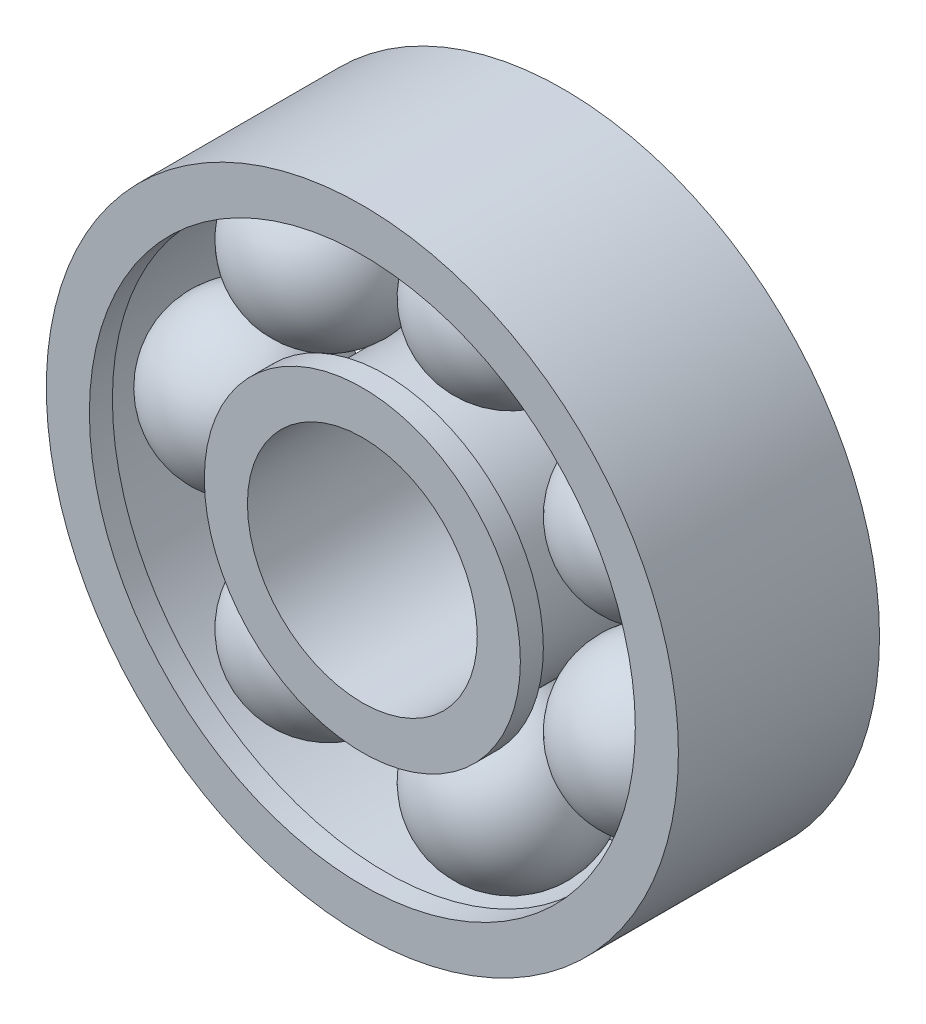
from build123d import *

# Parameters (mm, degrees)
BOSS_EXTRUDE1_DEPTH        = 3.5
BOSS_EXTRUDE1_DEPTH_BACK   = 3.5
SKETCH1_R                  = 5.5
SKETCH1_R_2                = 4
BOSS_EXTRUDE1_2_DEPTH      = 3.5
BOSS_EXTRUDE1_2_DEPTH_BACK = 3.5
SKETCH1_R_3                = 11
SKETCH1_R_4                = 9.5
CUT_EXTRUDE1_DEPTH         = 2.7
CUT_EXTRUDE1_DEPTH_BACK    = 2.7
SKETCH2_R                  = 10.3
SKETCH2_R_2                = 4.697673259


with BuildPart() as part:
    # Sketch1 → Boss-Extrude1 (new, two sides: drawn at the far end of the back side and taken through both)
    with BuildSketch(Plane.XY.offset(-BOSS_EXTRUDE1_DEPTH_BACK)):
        Circle(SKETCH1_R)
        Circle(SKETCH1_R_2, mode=Mode.SUBTRACT)
    extrude(amount=BOSS_EXTRUDE1_DEPTH + BOSS_EXTRUDE1_DEPTH_BACK)


with BuildPart() as body_2:
    # Sketch1 → Boss-Extrude1 2 (new, two sides: drawn at the far end of the back side and taken through both)
    with BuildSketch(Plane.XY.offset(-BOSS_EXTRUDE1_2_DEPTH_BACK)):
        Circle(SKETCH1_R_3)
        Circle(SKETCH1_R_4, mode=Mode.SUBTRACT)
    extrude(amount=BOSS_EXTRUDE1_2_DEPTH + BOSS_EXTRUDE1_2_DEPTH_BACK)


with BuildPart() as cut_extrude1_tool:
    # Sketch2 → Cut-Extrude1 (new, two sides: drawn at the far end of the back side and taken through both)
    with BuildSketch(Plane.XY.offset(-CUT_EXTRUDE1_DEPTH_BACK)):
        Circle(SKETCH2_R)
        Circle(SKETCH2_R_2, mode=Mode.SUBTRACT)
    extrude(amount=CUT_EXTRUDE1_DEPTH + CUT_EXTRUDE1_DEPTH_BACK)


with BuildPart() as part_1:
    add(part.part)

    # Cut-Extrude1: cut by cut_extrude1_tool
    add(cut_extrude1_tool.part, mode=Mode.SUBTRACT)


with BuildPart() as body_2_1:
    add(body_2.part)

    # Cut-Extrude1: cut by cut_extrude1_tool
    add(cut_extrude1_tool.part, mode=Mode.SUBTRACT)


with BuildPart() as body_3:
    # Sketch4 → Revolve2 (revolve)
    with BuildSketch(Plane.XY):
        with BuildLine():
            ThreePointArc((-7.498836629, -2.8), (-4.698836629, 0), (-7.498836629, 2.8))
            Line((-7.498836629, 2.8), (-7.498836629, -2.8))
        make_face()
    revolve(axis=Axis((-7.498836629, 0, 0), (0, 1, 0)))


with BuildPart() as body_4:
    # Sketch4_7 → Revolve3 (revolve)
    with BuildSketch(Plane.XY):
        with BuildLine():
            Line((-2.486320013, 7.608598004), (-4.675448164, 5.862826559))
            Line((-4.675448164, 5.862826559), (-6.864576315, 4.117055113))
            ThreePointArc((-6.864576315, 4.117055113), (-2.929676719, 3.673698408), (-2.486320013, 7.608598004))
        make_face()
    revolve(axis=Axis((-4.675448164, 5.862826559, 0), (0.7818314824680305, 0.6234898018587328, 0)))


with BuildPart() as body_5:
    # Sketch4_8 → Revolve4 (revolve)
    with BuildSketch(Plane.XY):
        with BuildLine():
            Line((4.398446284, 6.687766524), (1.66864813, 7.310825139))
            Line((1.66864813, 7.310825139), (-1.061150024, 7.933883754))
            ThreePointArc((-1.061150024, 7.933883754), (1.045589515, 4.581026985), (4.398446284, 6.687766524))
        make_face()
    revolve(axis=Axis((1.66864813, 7.310825139, 0), (0.974927912181823, -0.22252093395631764, 0)))


with BuildPart() as body_6:
    # Sketch4_9 → Revolve5 (revolve)
    with BuildSketch(Plane.XY):
        with BuildLine():
            Line((7.971092818, 0.730910446), (6.756218348, 3.253623276))
            Line((6.756218348, 3.253623276), (5.541343879, 5.776336106))
            ThreePointArc((5.541343879, 5.776336106), (4.233505518, 2.038748806), (7.971092818, 0.730910446))
        make_face()
    revolve(axis=Axis((6.756218348, 3.253623276, 0), (-0.4338837391175522, 0.900968867902422, 0)))


with BuildPart() as body_7:
    # Sketch4_10 → Revolve6 (revolve)
    with BuildSketch(Plane.XY):
        with BuildLine():
            Line((5.541343879, -5.776336106), (6.756218348, -3.253623276))
            Line((6.756218348, -3.253623276), (7.971092818, -0.730910446))
            ThreePointArc((7.971092818, -0.730910446), (4.233505518, -2.038748806), (5.541343879, -5.776336106))
        make_face()
    revolve(axis=Axis((6.756218348, -3.253623276, 0), (0.43388373911756595, 0.9009688679024154, 0)))


with BuildPart() as body_8:
    # Sketch4_11 → Revolve7 (revolve)
    with BuildSketch(Plane.XY):
        with BuildLine():
            Line((-1.061150024, -7.933883754), (1.66864813, -7.310825139))
            Line((1.66864813, -7.310825139), (4.398446284, -6.687766524))
            ThreePointArc((4.398446284, -6.687766524), (1.045589515, -4.581026985), (-1.061150024, -7.933883754))
        make_face()
    revolve(axis=Axis((1.66864813, -7.310825139, 0), (0.974927912181826, 0.2225209339563043, 0)))


with BuildPart() as body_9:
    # Sketch4_12 → Revolve8 (revolve)
    with BuildSketch(Plane.XY):
        with BuildLine():
            Line((-6.864576315, -4.117055113), (-4.675448164, -5.862826559))
            Line((-4.675448164, -5.862826559), (-2.486320013, -7.608598004))
            ThreePointArc((-2.486320013, -7.608598004), (-2.929676719, -3.673698408), (-6.864576315, -4.117055113))
        make_face()
    revolve(axis=Axis((-4.675448164, -5.862826559, 0), (-0.7818314824680226, 0.6234898018587426, 0)))


solid = Compound([part_1.part, body_2_1.part, body_3.part, body_4.part, body_5.part, body_6.part, body_7.part, body_8.part, body_9.part])
